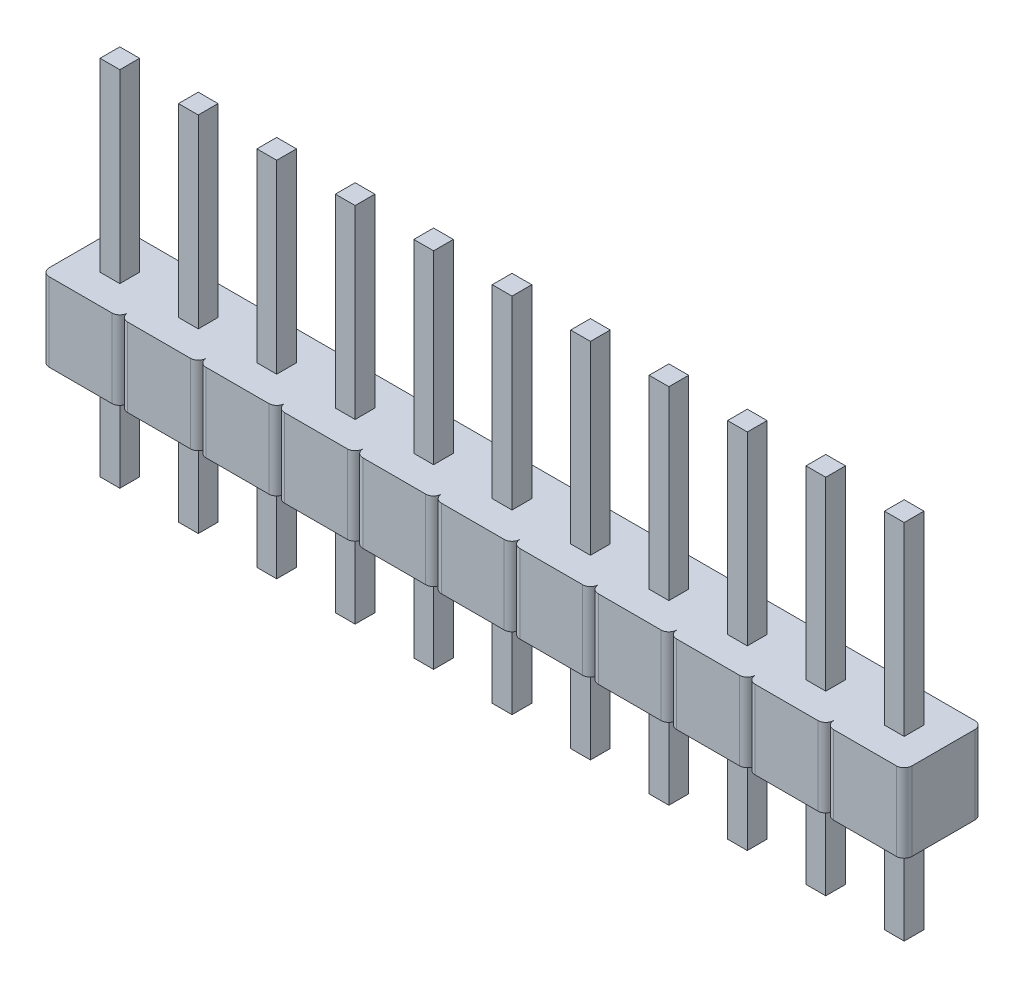
from build123d import *

# Parameters (mm, degrees)
BOSS_EXTRUDE1_DEPTH      = 2.54
SKETCH2_W                = 0.64
SKETCH2_H                = 0.64
BOSS_EXTRUDE2_DEPTH      = 6
BOSS_EXTRUDE2_DEPTH_BACK = 5.74


with BuildPart() as part:
    # Sketch1 → Boss-Extrude1 (new body)
    with BuildSketch(Plane(origin=(0, 0, 0), x_dir=(1, 0, 0), z_dir=(0, 1, 0))):
        with BuildLine():
            Line((-11.43, -1.016), (-11.43, 1.016))
            ThreePointArc((-11.43, 1.016), (-11.504394878, 1.195605122), (-11.684, 1.27))
            Line((-11.684, 1.27), (-13.716, 1.27))
            ThreePointArc((-13.716, 1.27), (-13.895605122, 1.195605122), (-13.97, 1.016))
            Line((-13.97, 1.016), (-13.97, -1.016))
            ThreePointArc((-13.97, -1.016), (-13.895605122, -1.195605122), (-13.716, -1.27))
            Line((-13.716, -1.27), (-11.684, -1.27))
            ThreePointArc((-11.684, -1.27), (-11.504394878, -1.195605122), (-11.43, -1.016))
        make_face()
        with BuildLine():
            Line((-8.89, -1.016), (-8.89, 1.016))
            ThreePointArc((-8.89, 1.016), (-8.964394878, 1.195605122), (-9.144, 1.27))
            Line((-9.144, 1.27), (-11.176, 1.27))
            ThreePointArc((-11.176, 1.27), (-11.355605122, 1.195605122), (-11.43, 1.016))
            Line((-11.43, 1.016), (-11.43, -1.016))
            ThreePointArc((-11.43, -1.016), (-11.355605122, -1.195605122), (-11.176, -1.27))
            Line((-11.176, -1.27), (-9.144, -1.27))
            ThreePointArc((-9.144, -1.27), (-8.964394878, -1.195605122), (-8.89, -1.016))
        make_face()
        with BuildLine():
            Line((-6.35, -1.016), (-6.35, 1.016))
            ThreePointArc((-6.35, 1.016), (-6.424394878, 1.195605122), (-6.604, 1.27))
            Line((-6.604, 1.27), (-8.636, 1.27))
            ThreePointArc((-8.636, 1.27), (-8.815605122, 1.195605122), (-8.89, 1.016))
            Line((-8.89, 1.016), (-8.89, -1.016))
            ThreePointArc((-8.89, -1.016), (-8.815605122, -1.195605122), (-8.636, -1.27))
            Line((-8.636, -1.27), (-6.604, -1.27))
            ThreePointArc((-6.604, -1.27), (-6.424394878, -1.195605122), (-6.35, -1.016))
        make_face()
        with BuildLine():
            Line((-3.81, -1.016), (-3.81, 1.016))
            ThreePointArc((-3.81, 1.016), (-3.884394878, 1.195605122), (-4.064, 1.27))
            Line((-4.064, 1.27), (-6.096, 1.27))
            ThreePointArc((-6.096, 1.27), (-6.275605122, 1.195605122), (-6.35, 1.016))
            Line((-6.35, 1.016), (-6.35, -1.016))
            ThreePointArc((-6.35, -1.016), (-6.275605122, -1.195605122), (-6.096, -1.27))
            Line((-6.096, -1.27), (-4.064, -1.27))
            ThreePointArc((-4.064, -1.27), (-3.884394878, -1.195605122), (-3.81, -1.016))
        make_face()
        with BuildLine():
            Line((-1.27, -1.016), (-1.27, 1.016))
            ThreePointArc((-1.27, 1.016), (-1.344394878, 1.195605122), (-1.524, 1.27))
            Line((-1.524, 1.27), (-3.556, 1.27))
            ThreePointArc((-3.556, 1.27), (-3.735605122, 1.195605122), (-3.81, 1.016))
            Line((-3.81, 1.016), (-3.81, -1.016))
            ThreePointArc((-3.81, -1.016), (-3.735605122, -1.195605122), (-3.556, -1.27))
            Line((-3.556, -1.27), (-1.524, -1.27))
            ThreePointArc((-1.524, -1.27), (-1.344394878, -1.195605122), (-1.27, -1.016))
        make_face()
        with BuildLine():
            Line((1.27, -1.016), (1.27, 1.016))
            ThreePointArc((1.27, 1.016), (1.195605122, 1.195605122), (1.016, 1.27))
            Line((1.016, 1.27), (-1.016, 1.27))
            ThreePointArc((-1.016, 1.27), (-1.195605122, 1.195605122), (-1.27, 1.016))
            Line((-1.27, 1.016), (-1.27, -1.016))
            ThreePointArc((-1.27, -1.016), (-1.195605122, -1.195605122), (-1.016, -1.27))
            Line((-1.016, -1.27), (1.016, -1.27))
            ThreePointArc((1.016, -1.27), (1.195605122, -1.195605122), (1.27, -1.016))
        make_face()
        with BuildLine():
            Line((3.81, -1.016), (3.81, 1.016))
            ThreePointArc((3.81, 1.016), (3.735605122, 1.195605122), (3.556, 1.27))
            Line((3.556, 1.27), (1.524, 1.27))
            ThreePointArc((1.524, 1.27), (1.344394878, 1.195605122), (1.27, 1.016))
            Line((1.27, 1.016), (1.27, -1.016))
            ThreePointArc((1.27, -1.016), (1.344394878, -1.195605122), (1.524, -1.27))
            Line((1.524, -1.27), (3.556, -1.27))
            ThreePointArc((3.556, -1.27), (3.735605122, -1.195605122), (3.81, -1.016))
        make_face()
        with BuildLine():
            Line((6.35, -1.016), (6.35, 1.016))
            ThreePointArc((6.35, 1.016), (6.275605122, 1.195605122), (6.096, 1.27))
            Line((6.096, 1.27), (4.064, 1.27))
            ThreePointArc((4.064, 1.27), (3.884394878, 1.195605122), (3.81, 1.016))
            Line((3.81, 1.016), (3.81, -1.016))
            ThreePointArc((3.81, -1.016), (3.884394878, -1.195605122), (4.064, -1.27))
            Line((4.064, -1.27), (6.096, -1.27))
            ThreePointArc((6.096, -1.27), (6.275605122, -1.195605122), (6.35, -1.016))
        make_face()
        with BuildLine():
            Line((8.89, -1.016), (8.89, 1.016))
            ThreePointArc((8.89, 1.016), (8.815605122, 1.195605122), (8.636, 1.27))
            Line((8.636, 1.27), (6.604, 1.27))
            ThreePointArc((6.604, 1.27), (6.424394878, 1.195605122), (6.35, 1.016))
            Line((6.35, 1.016), (6.35, -1.016))
            ThreePointArc((6.35, -1.016), (6.424394878, -1.195605122), (6.604, -1.27))
            Line((6.604, -1.27), (8.636, -1.27))
            ThreePointArc((8.636, -1.27), (8.815605122, -1.195605122), (8.89, -1.016))
        make_face()
        with BuildLine():
            Line((11.43, -1.016), (11.43, 1.016))
            ThreePointArc((11.43, 1.016), (11.355605122, 1.195605122), (11.176, 1.27))
            Line((11.176, 1.27), (9.144, 1.27))
            ThreePointArc((9.144, 1.27), (8.964394878, 1.195605122), (8.89, 1.016))
            Line((8.89, 1.016), (8.89, -1.016))
            ThreePointArc((8.89, -1.016), (8.964394878, -1.195605122), (9.144, -1.27))
            Line((9.144, -1.27), (11.176, -1.27))
            ThreePointArc((11.176, -1.27), (11.355605122, -1.195605122), (11.43, -1.016))
        make_face()
        with BuildLine():
            Line((13.97, -1.016), (13.97, 1.016))
            ThreePointArc((13.97, 1.016), (13.895605122, 1.195605122), (13.716, 1.27))
            Line((13.716, 1.27), (11.684, 1.27))
            ThreePointArc((11.684, 1.27), (11.504394878, 1.195605122), (11.43, 1.016))
            Line((11.43, 1.016), (11.43, -1.016))
            ThreePointArc((11.43, -1.016), (11.504394878, -1.195605122), (11.684, -1.27))
            Line((11.684, -1.27), (13.716, -1.27))
            ThreePointArc((13.716, -1.27), (13.895605122, -1.195605122), (13.97, -1.016))
        make_face()
    extrude(amount=BOSS_EXTRUDE1_DEPTH)

    # Sketch2 → Boss-Extrude2 (add, two sides)
    with BuildSketch(Plane(origin=(0, 2.54, 0), x_dir=(1, 0, 0), z_dir=(0, 1, 0))) as boss_extrude2_sk:
        with Locations((-12.7, 0)):
            Rectangle(SKETCH2_W, SKETCH2_H)
        with Locations((-10.16, 0)):
            Rectangle(SKETCH2_W, SKETCH2_H)
        with Locations((-7.62, 0)):
            Rectangle(SKETCH2_W, SKETCH2_H)
        with Locations((-5.08, 0)):
            Rectangle(SKETCH2_W, SKETCH2_H)
        with Locations((-2.54, 0)):
            Rectangle(SKETCH2_W, SKETCH2_H)
        Rectangle(SKETCH2_W, SKETCH2_H)
        with Locations((2.54, 0)):
            Rectangle(SKETCH2_W, SKETCH2_H)
        with Locations((5.08, 0)):
            Rectangle(SKETCH2_W, SKETCH2_H)
        with Locations((7.62, 0)):
            Rectangle(SKETCH2_W, SKETCH2_H)
        with Locations((10.16, 0)):
            Rectangle(SKETCH2_W, SKETCH2_H)
        with Locations((12.7, 0)):
            Rectangle(SKETCH2_W, SKETCH2_H)
    extrude(amount=BOSS_EXTRUDE2_DEPTH)
    extrude(boss_extrude2_sk.sketch, amount=-BOSS_EXTRUDE2_DEPTH_BACK)


solid = part.part
